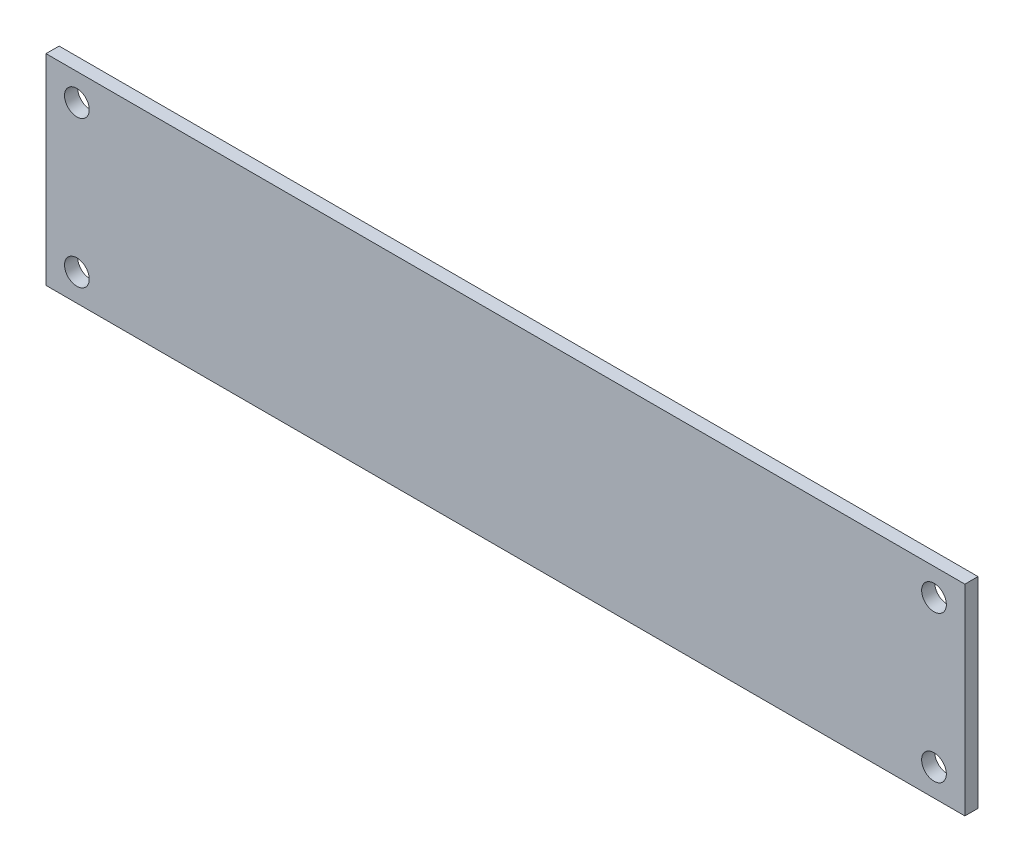
from build123d import *

# Parameters (mm, degrees)
SKETCH1_W  = 119
SKETCH1_H  = 26
SKETCH1_R  = 1.6
MAIN_DEPTH = 1.7


with BuildPart() as part:
    # Sketch1 → Main (new body)
    with BuildSketch(Plane.XY):
        Rectangle(SKETCH1_W, SKETCH1_H)
        with Locations((-55.5, 9.5)):
            Circle(SKETCH1_R, mode=Mode.SUBTRACT)
        with Locations((-55.5, -9.5)):
            Circle(SKETCH1_R, mode=Mode.SUBTRACT)
        with Locations((55.5, -9.5)):
            Circle(SKETCH1_R, mode=Mode.SUBTRACT)
        with Locations((55.5, 9.5)):
            Circle(SKETCH1_R, mode=Mode.SUBTRACT)
    extrude(amount=MAIN_DEPTH)


solid = part.part
